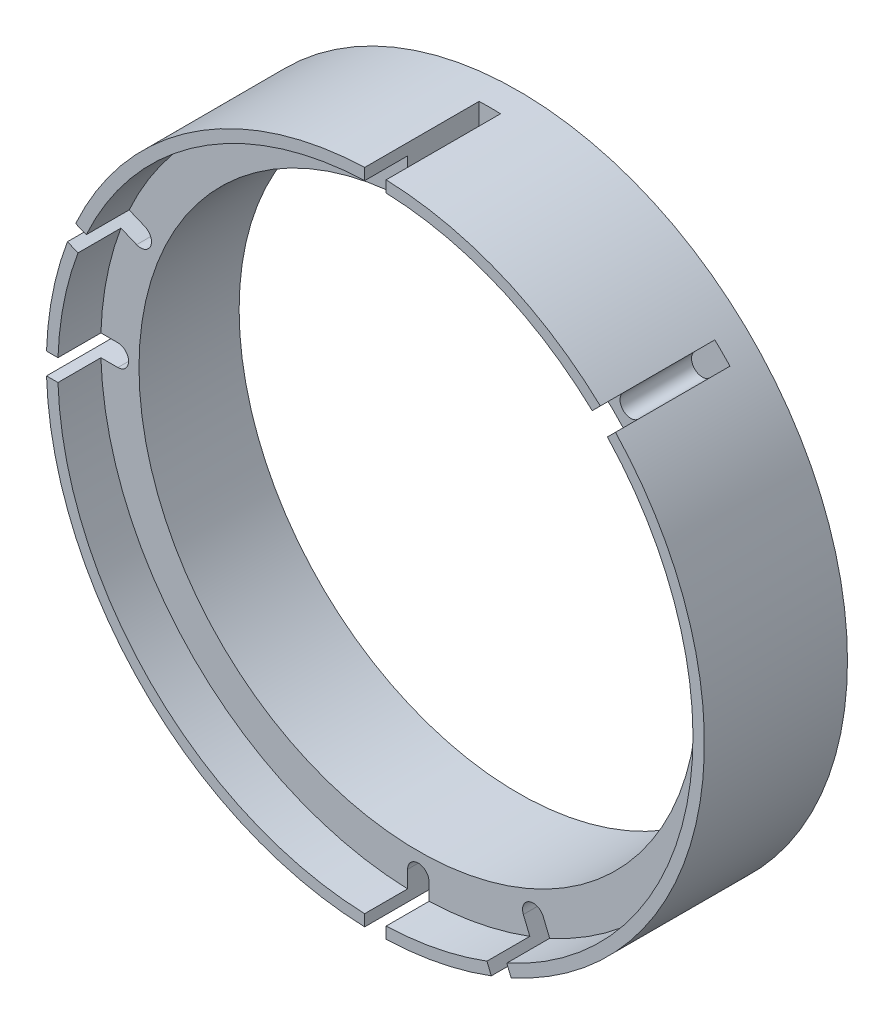
from build123d import *

# Parameters (mm, degrees)
SKETCH1_R           = 23
BOSS_EXTRUDE1_DEPTH = 5
SKETCH2_R           = 22.2
CUT_EXTRUDE1_DEPTH  = 3
SKETCH3_R           = 19.525
CUT_EXTRUDE2_DEPTH  = 7
CUT_EXTRUDE4_DEPTH  = 8
CIRPATTERN1_COUNT   = 16


with BuildPart() as part:
    # Sketch1 → Boss-Extrude1 (new body, symmetric)
    with BuildSketch(Plane.XY):
        Circle(SKETCH1_R)
    extrude(amount=BOSS_EXTRUDE1_DEPTH, both=True)

    # Sketch2 → Cut-Extrude1 (cut)
    with BuildSketch(Plane.XY.offset(5)):
        Circle(SKETCH2_R)
    extrude(amount=-CUT_EXTRUDE1_DEPTH, mode=Mode.SUBTRACT)

    # Sketch3 → Cut-Extrude2 (cut)
    with BuildSketch(Plane(origin=(0, 0, -5), x_dir=(-1, 0, 0), z_dir=(0, 0, -1))):
        Circle(SKETCH3_R)
    extrude(amount=-CUT_EXTRUDE2_DEPTH, mode=Mode.SUBTRACT)

    # Sketch5 → Cut-Extrude4 (cut)
    with BuildSketch(Plane.XY.offset(5)):
        with BuildLine():
            Line((-23, 0.75), (-21, 0.75))
            ThreePointArc((-21, 0.75), (-20.25, 0), (-21, -0.75))
            Line((-21, -0.75), (-23, -0.75))
            ThreePointArc((-23, -0.75), (-23.75, 0), (-23, 0.75))
        make_face()
    cut_extrude4 = extrude(amount=-CUT_EXTRUDE4_DEPTH, mode=Mode.SUBTRACT)

    # CirPattern1: Cut-Extrude4 ×16 about axis, 10 skipped
    cirpattern1_axis = Axis((0, 0, 5), (0, 0, 1))
    add([cut_extrude4.rotate(cirpattern1_axis, i * 360 / CIRPATTERN1_COUNT) for i in range(1, CIRPATTERN1_COUNT) if i not in (1, 2, 3, 6, 7, 8, 9, 11, 13, 14)], mode=Mode.SUBTRACT)


solid = part.part
